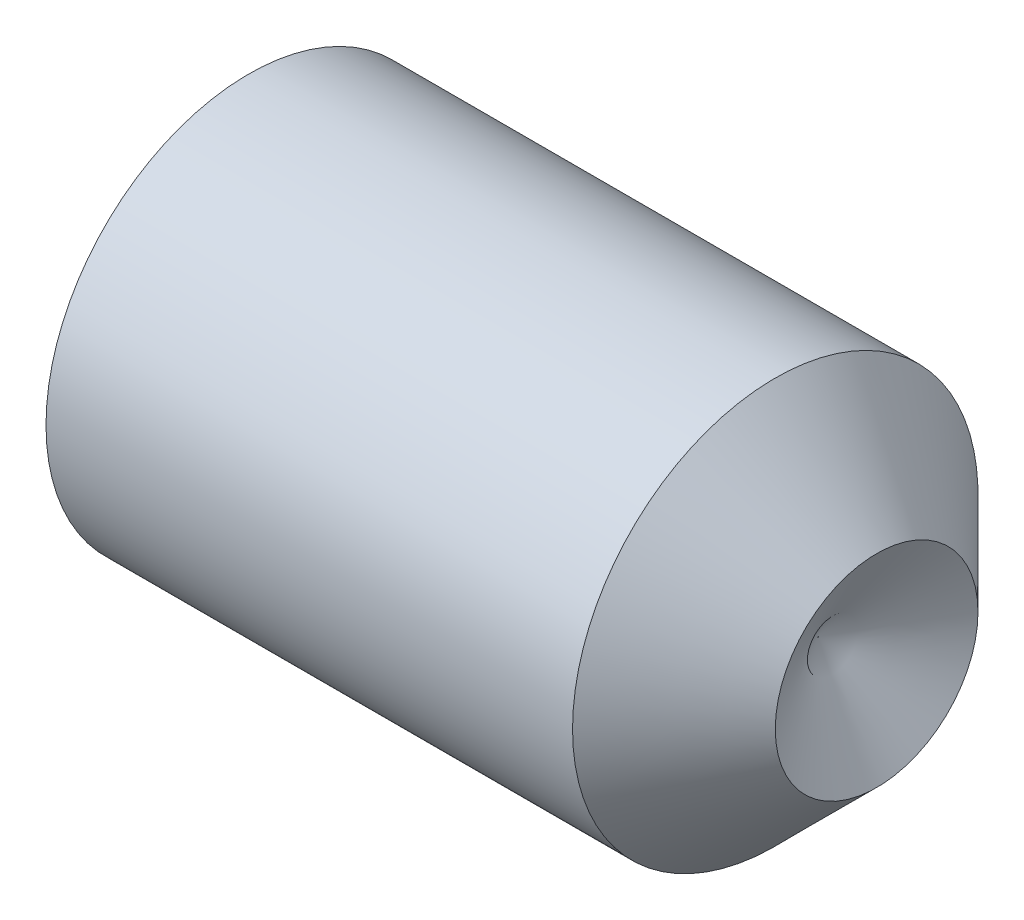
from build123d import *

# Parameters (mm, degrees)
HEX_2_DEPTH = 3


with BuildPart() as part:
    # BodySke → BaseBody (revolve)
    with BuildSketch(Plane.XY):
        Polygon((0, 0), (0, 2.055), (0.25692087, 2.5), (6.75, 2.5), (8, 1.25), (7.278312164, 0), align=None)
    revolve(axis=Axis((-12.7, 0, 0), (1, 0, 0)))

    # Sketch2 → Hex 2 (cut)
    with BuildSketch(Plane.ZY):
        Polygon((0.721687836, 1.25), (-0.721687836, 1.25), (-1.443375673, 0), (-0.721687836, -1.25), (0.721687836, -1.25), (1.443375673, 0), align=None)
    extrude(amount=-HEX_2_DEPTH, mode=Mode.SUBTRACT)


solid = part.part
